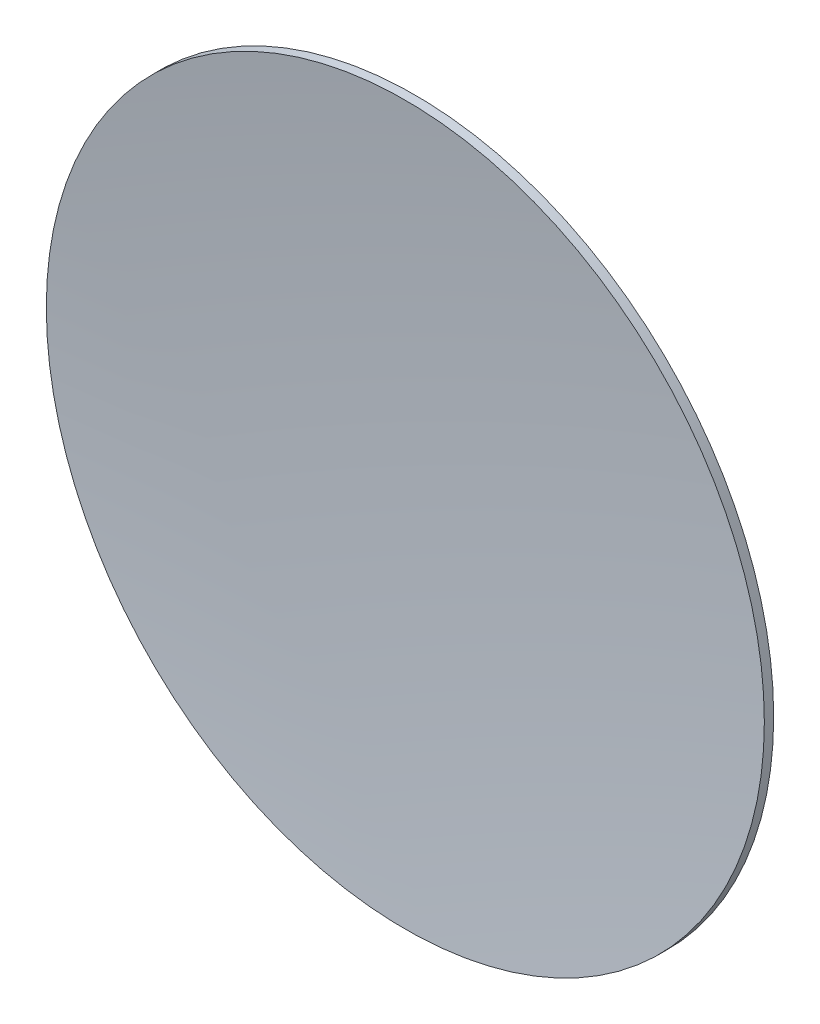
from build123d import *

# Parameters (mm, degrees)
SKETCH1_R           = 19.3
BOSS_EXTRUDE1_DEPTH = 2


with BuildPart() as part:
    # Sketch1 → Boss-Extrude1 (new body)
    with BuildSketch(Plane.XY):
        Circle(SKETCH1_R)
    extrude(amount=BOSS_EXTRUDE1_DEPTH)

    # Sketch2 → Cut-Revolve1 (revolve, cut)
    with BuildSketch(Plane(origin=(0, 0, 0), x_dir=(1, 0, 0), z_dir=(0, 1, 0))):
        with BuildLine():
            Line((20.341497367, -1.11117089), (20.341497367, 2.053240221))
            Line((20.341497367, 2.053240221), (0, 2.27173347))
            Line((0, 2.27173347), (0, 0))
            ThreePointArc((0, 0), (10.185912034, -0.277999646), (20.341497367, -1.11117089))
        make_face()
        with BuildLine():
            Line((0, -0.5), (0, -3.774302912))
            Line((0, -3.774302912), (20.278222945, -3.774302912))
            Line((20.278222945, -3.774302912), (20.287034069, -1.608195788))
            ThreePointArc((20.287034069, -1.608195788), (10.158639786, -0.777255316), (0, -0.5))
        make_face()
    revolve(axis=Axis((0, 0, -2.27173347), (0, 0, 1)), mode=Mode.SUBTRACT)


solid = part.part
